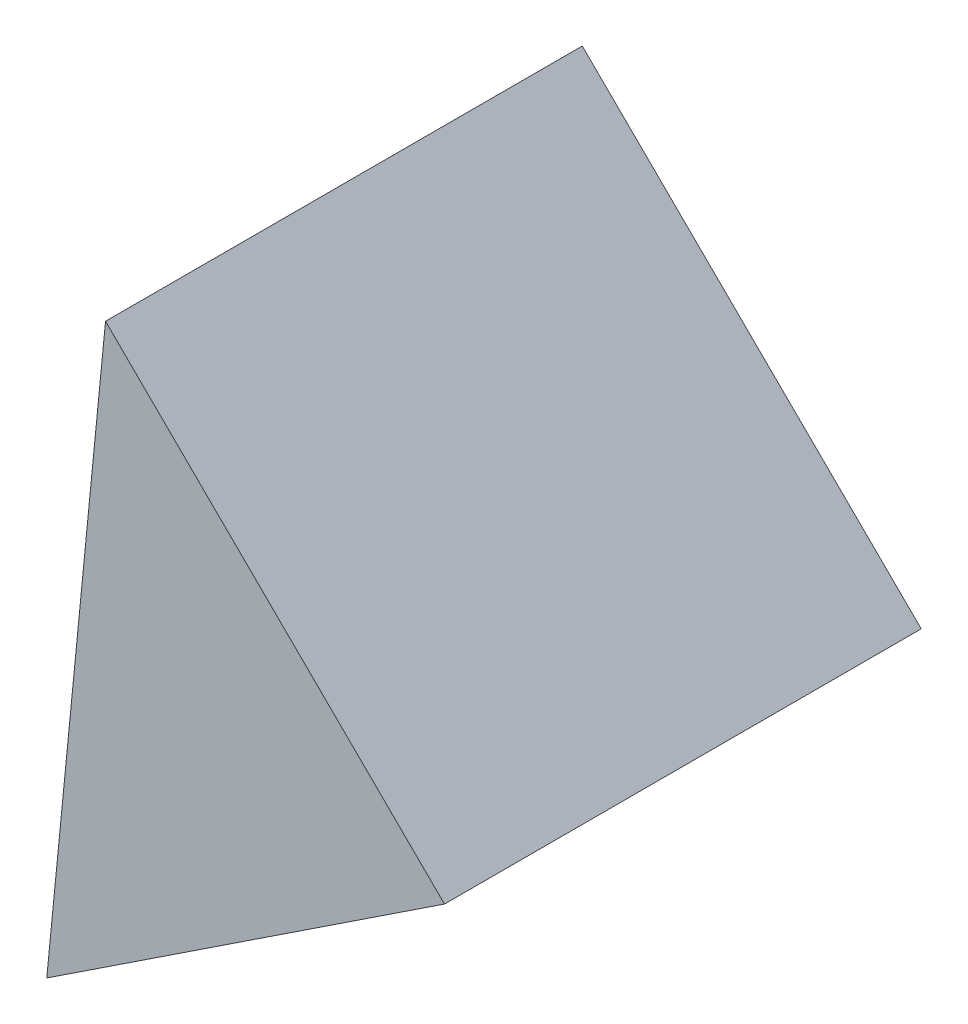
from build123d import *

# Parameters (mm, degrees)
EXTRUDE_1_DEPTH = 12.5


with BuildPart() as part:
    # 草图2 → 凸台-拉伸1 (new body)
    with BuildSketch(Plane.XY):
        Polygon((11.114170821, 7.73999018), (2.227010526, 16.530233743), (0.686170974, 0.847471105), align=None)
    extrude(amount=EXTRUDE_1_DEPTH)


solid = part.part
